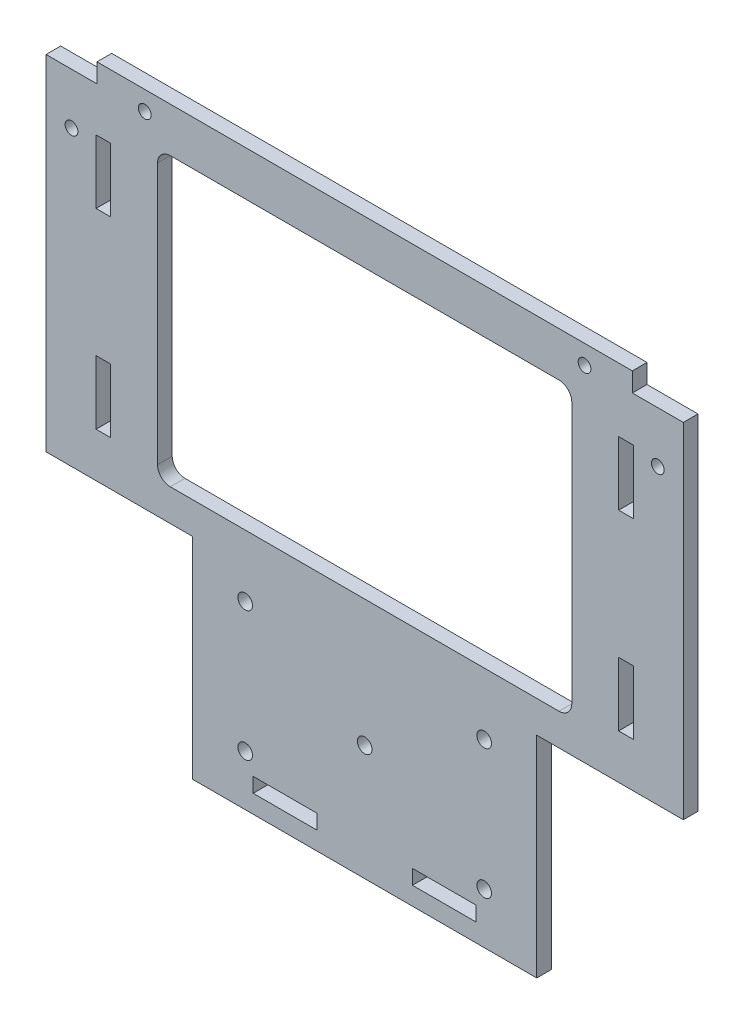
from build123d import *

# Parameters (mm, degrees)
BOSS_EXTRUDE1_DEPTH = 2.3
SKETCH5_W           = 65
SKETCH5_H           = 45
CUT_EXTRUDE1_DEPTH  = 3.3
FILLET1_R           = 2
SKETCH7_W           = 2.3
SKETCH7_H           = 10
SKETCH7_W_2         = 10
SKETCH7_H_2         = 2.3
CUT_EXTRUDE2_DEPTH  = 3.3
SKETCH8_R           = 1
CUT_EXTRUDE3_DEPTH  = 3.3
SKETCH10_R          = 1.15
CUT_EXTRUDE4_DEPTH  = 3.3
SKETCH11_W          = 8
SKETCH11_H          = 3
CUT_EXTRUDE5_DEPTH  = 10
SKETCH12_R          = 1
CUT_EXTRUDE6_DEPTH  = 10


with BuildPart() as part:
    # Sketch1 → Boss-Extrude1 (new body)
    with BuildSketch(Plane.XY):
        Polygon((0, 0), (100, 0), (100, -57), (77, -57), (77, -90), (23, -90), (23, -57), (0, -57), align=None)
    extrude(amount=BOSS_EXTRUDE1_DEPTH)

    # Sketch5 → Cut-Extrude1 (cut, through all)
    with BuildSketch(Plane.XY.offset(2.3)):
        with Locations((50, -29.5)):
            Rectangle(SKETCH5_W, SKETCH5_H)
    extrude(amount=-CUT_EXTRUDE1_DEPTH, mode=Mode.SUBTRACT)

    # Fillet1
    fillet1_edges = [part.edges().sort_by_distance(p)[0] for p in [
        (82.5, -7, 1.15),
        (82.5, -52, 1.15),
        (17.5, -52, 1.15),
        (17.5, -7, 1.15),
    ]]
    fillet(fillet1_edges, radius=FILLET1_R)

    # Sketch7 → Cut-Extrude2 (cut, through all)
    with BuildSketch(Plane.XY.offset(2.3)):
        with Locations((91, -15)):
            Rectangle(SKETCH7_W, SKETCH7_H)
        with Locations((91, -45)):
            Rectangle(SKETCH7_W, SKETCH7_H)
        with Locations((9, -15)):
            Rectangle(SKETCH7_W, SKETCH7_H)
        with Locations((9, -45)):
            Rectangle(SKETCH7_W, SKETCH7_H)
        with Locations((37.5, -86)):
            Rectangle(SKETCH7_W_2, SKETCH7_H_2)
        with Locations((62.5, -86)):
            Rectangle(SKETCH7_W_2, SKETCH7_H_2)
    extrude(amount=-CUT_EXTRUDE2_DEPTH, mode=Mode.SUBTRACT)

    # Sketch8 → Cut-Extrude3 (cut, through all)
    with BuildSketch(Plane.XY.offset(2.3)):
        with Locations((15.5, -3)):
            Circle(SKETCH8_R)
        with Locations((84.5, -3)):
            Circle(SKETCH8_R)
    extrude(amount=-CUT_EXTRUDE3_DEPTH, mode=Mode.SUBTRACT)

    # Sketch10 → Cut-Extrude4 (cut, through all)
    with BuildSketch(Plane.XY.offset(2.3)):
        with Locations((49.9996888, -71.875)):
            Circle(SKETCH10_R)
        with Locations((31.2496888, -61.7)):
            Circle(SKETCH10_R)
        with Locations((68.7496888, -61.7)):
            Circle(SKETCH10_R)
        with Locations((31.2496888, -82.05)):
            Circle(SKETCH10_R)
        with Locations((68.7496888, -82.05)):
            Circle(SKETCH10_R)
    extrude(amount=-CUT_EXTRUDE4_DEPTH, mode=Mode.SUBTRACT)

    # Sketch11 → Cut-Extrude5 (cut)
    with BuildSketch(Plane.XY.offset(2.3)):
        with Locations((4, -1.5)):
            Rectangle(SKETCH11_W, SKETCH11_H)
        with Locations((96, -1.5)):
            Rectangle(SKETCH11_W, SKETCH11_H)
    extrude(amount=-CUT_EXTRUDE5_DEPTH, mode=Mode.SUBTRACT)

    # Sketch12 → Cut-Extrude6 (cut)
    with BuildSketch(Plane.XY.offset(2.3)):
        with Locations((4, -11)):
            Circle(SKETCH12_R)
        with Locations((96, -11)):
            Circle(SKETCH12_R)
    extrude(amount=-CUT_EXTRUDE6_DEPTH, mode=Mode.SUBTRACT)


solid = part.part
